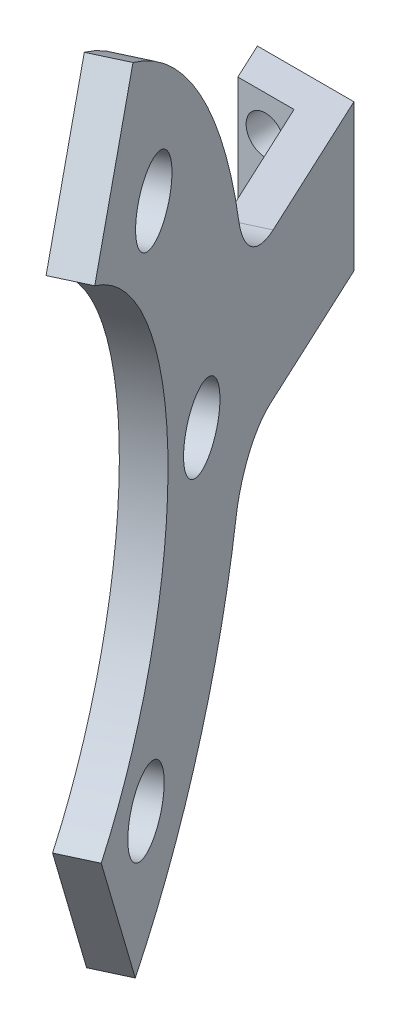
from build123d import *

# Parameters (mm, degrees)
BOSS_EXTRUDE1_DEPTH     = 8
BOSS_EXTRUDE2_DEPTH     = 2
SKETCH3_R               = 2.05
CUT_EXTRUDE3_DEPTH      = 10
CUT_EXTRUDE3_DEPTH_BACK = 10
FILLET2_R               = 4
SKETCH6_R               = 1.05
CUT_EXTRUDE4_DEPTH      = 3


with BuildPart() as part:
    # Sketch1 → Boss-Extrude1 (new body)
    with BuildSketch(Plane(origin=(0, 0, 0), x_dir=(1, 0, 0), z_dir=(0, 1, 0))):
        Polygon((34.518104392, -15.549979118), (32.760161227, -16.503727422), (25.996962058, -2), (22.929577374, -2), (21.996962058, 0), (27.267030045, 0), align=None)
    extrude(amount=BOSS_EXTRUDE1_DEPTH)

    # Sketch5 → Boss-Extrude2 (add)
    with BuildSketch(Plane(origin=(22.396969556, 0, -10.443878423), x_dir=(-0.422618262, 0, -0.906307787), z_dir=(0.906307787, 0, -0.422618262))):
        with BuildLine():
            Line((-40.780850255, 18.736062391), (-36.467218683, 26.428860828))
            ThreePointArc((-36.467218683, 26.428860828), (-23.692308478, 4.771999965), (-36.205658542, -17.037035395))
            Line((-36.205658542, -17.037035395), (-40.049339329, -9.057253488))
            ThreePointArc((-40.049339329, -9.057253488), (-32.517126315, 5.047276383), (-40.780850255, 18.736062391))
        make_face()
    extrude(amount=-BOSS_EXTRUDE2_DEPTH)

    # Sketch3 → Cut-Extrude3 (cut, two sides)
    with BuildSketch(Plane(origin=(20.587699136, 0, -9.600201771), x_dir=(0.422618262, 0, 0.906307787), z_dir=(-0.906307787, 0, 0.422618262))) as cut_extrude3_sk:
        with Locations((28.701516689, 4)):
            Circle(SKETCH3_R)
        with Locations((34.117040182, 18.317355913)):
            Circle(SKETCH3_R)
        with Locations((48.070293023, 24.611901983)):
            Circle(SKETCH3_R)
        with Locations((62.387648936, 19.19637849)):
            Circle(SKETCH3_R)
        with Locations((68.682195005, 5.243125649)):
            Circle(SKETCH3_R)
        with Locations((63.266671512, -9.074230264)):
            Circle(SKETCH3_R)
        with Locations((49.313418672, -15.368776333)):
            Circle(SKETCH3_R)
        with Locations((34.996062759, -9.953252841)):
            Circle(SKETCH3_R)
    extrude(amount=CUT_EXTRUDE3_DEPTH, mode=Mode.SUBTRACT)
    extrude(cut_extrude3_sk.sketch, amount=-CUT_EXTRUDE3_DEPTH_BACK, mode=Mode.SUBTRACT)

    # Fillet2
    fillet2_edges = [part.edges().sort_by_distance(p)[0] for p in [
        (31.687047343, 0, 11.840592477),
        (31.60186373, 8, 11.657915631),
    ]]
    fillet(fillet2_edges, radius=FILLET2_R)

    # Sketch6 → Cut-Extrude4 (cut, through all)
    with BuildSketch(Plane.XY.offset(2)):
        with Locations((24.429577374, 6)):
            Circle(SKETCH6_R)
        with Locations((24.429577374, 2)):
            Circle(SKETCH6_R)
    extrude(amount=-CUT_EXTRUDE4_DEPTH, mode=Mode.SUBTRACT)


solid = part.part
